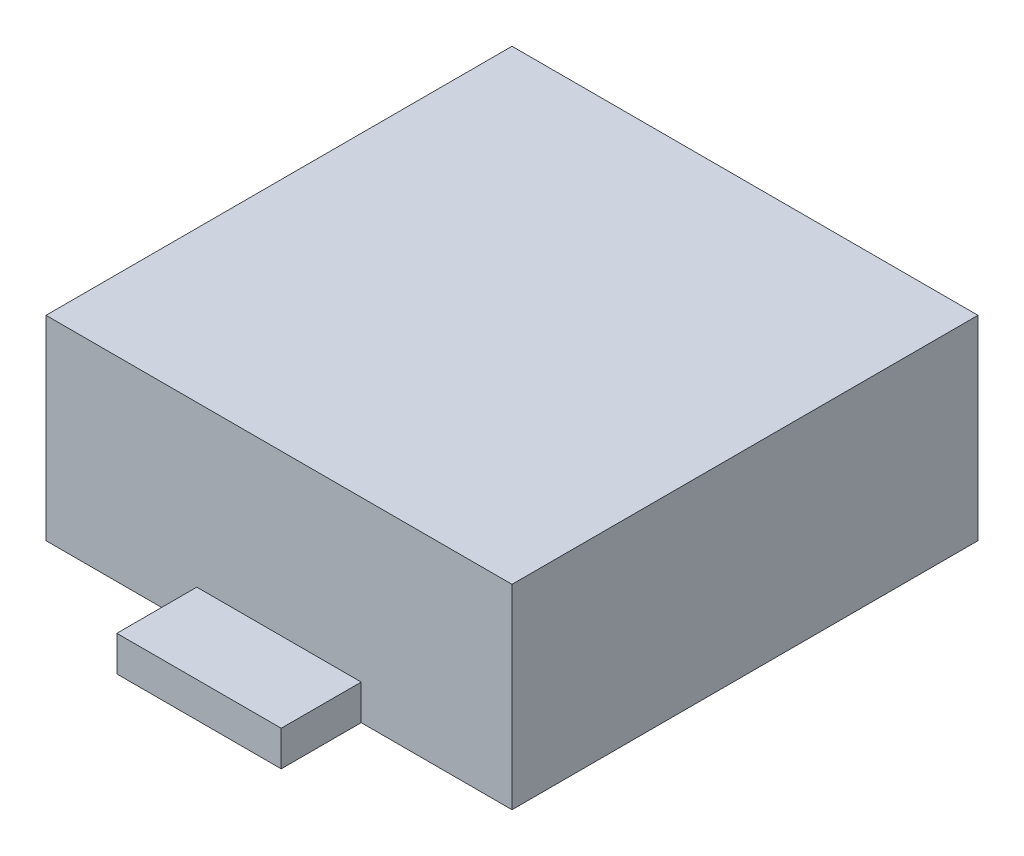
from build123d import *

# Parameters (mm, degrees)
SKETCH1_W           = 74
SKETCH1_H           = 74
BOSS_EXTRUDE1_DEPTH = 31
SKETCH2_W           = 26.106590286
SKETCH2_H           = 5.588637075
BOSS_EXTRUDE2_DEPTH = 12.7


with BuildPart() as part:
    # Sketch1 → Boss-Extrude1 (new body)
    with BuildSketch(Plane(origin=(0, 0, 0), x_dir=(1, 0, 0), z_dir=(0, 1, 0))):
        with Locations((37, 37)):
            Rectangle(SKETCH1_W, SKETCH1_H)
    extrude(amount=BOSS_EXTRUDE1_DEPTH)

    # Sketch2 → Boss-Extrude2 (add)
    with BuildSketch(Plane.XY):
        with Locations((37, 2.794318538)):
            Rectangle(SKETCH2_W, SKETCH2_H)
    extrude(amount=BOSS_EXTRUDE2_DEPTH)


solid = part.part
